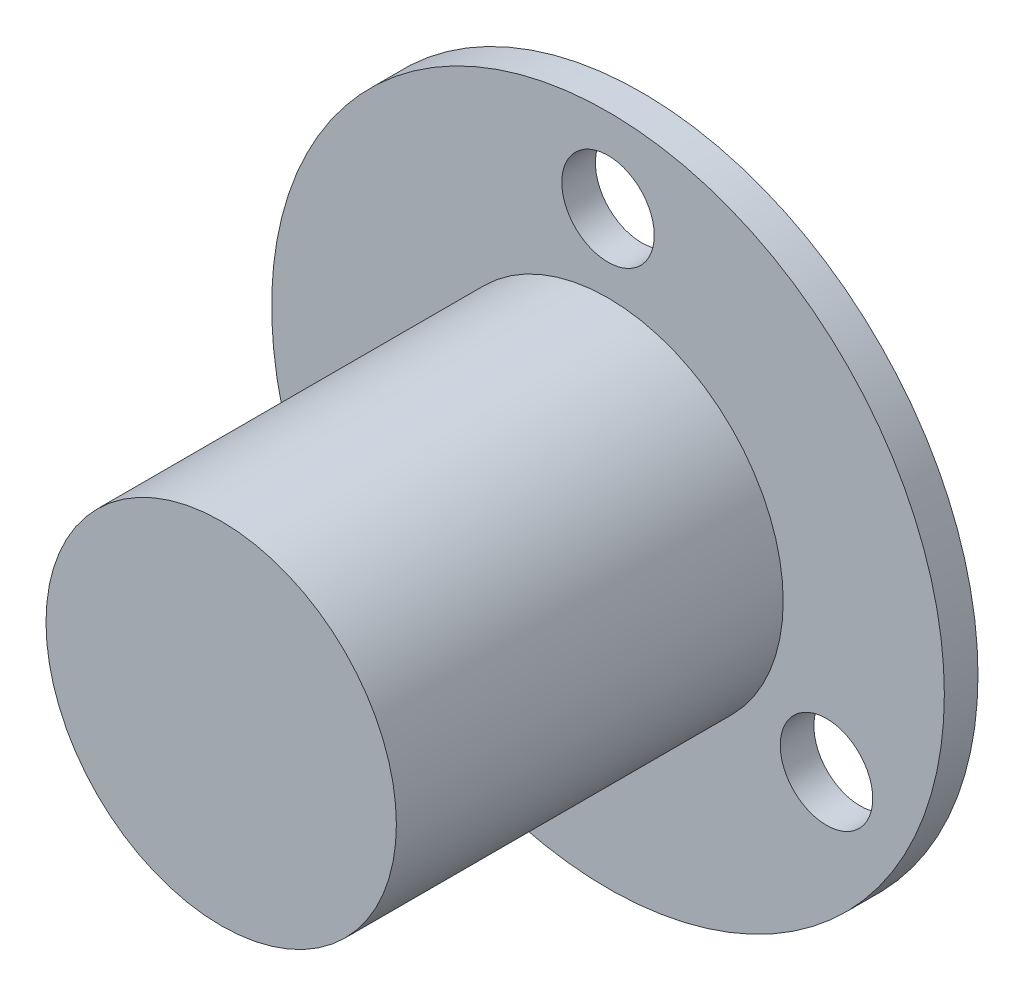
from build123d import *

# Parameters (mm, degrees)
SKETCH1_R           = 12
BOSS_EXTRUDE1_DEPTH = 1.2
SKETCH2_R           = 6.25
BOSS_EXTRUDE2_DEPTH = 13.8
SKETCH3_R           = 1.65
CUT_EXTRUDE1_DEPTH  = 2.2
SKETCH4_R           = 2.5
BOSS_EXTRUDE3_DEPTH = 1.5


with BuildPart() as part:
    # Sketch1 → Boss-Extrude1 (new body)
    with BuildSketch(Plane.XY):
        Circle(SKETCH1_R)
    extrude(amount=BOSS_EXTRUDE1_DEPTH)

    # Sketch2 → Boss-Extrude2 (add)
    with BuildSketch(Plane.XY.offset(1.2)):
        Circle(SKETCH2_R)
    extrude(amount=BOSS_EXTRUDE2_DEPTH)

    # Sketch3 → Cut-Extrude1 (cut, through all)
    with BuildSketch(Plane.XY.offset(1.2)):
        with Locations((0, 9)):
            Circle(SKETCH3_R)
        with Locations((7.794228634, -4.5)):
            Circle(SKETCH3_R)
        with Locations((-7.794228634, -4.5)):
            Circle(SKETCH3_R)
    extrude(amount=-CUT_EXTRUDE1_DEPTH, mode=Mode.SUBTRACT)

    # Sketch4 → Boss-Extrude3 (add)
    with BuildSketch(Plane(origin=(0, 0, 0), x_dir=(-1, 0, 0), z_dir=(0, 0, -1))):
        Circle(SKETCH4_R)
    extrude(amount=BOSS_EXTRUDE3_DEPTH)


solid = part.part
